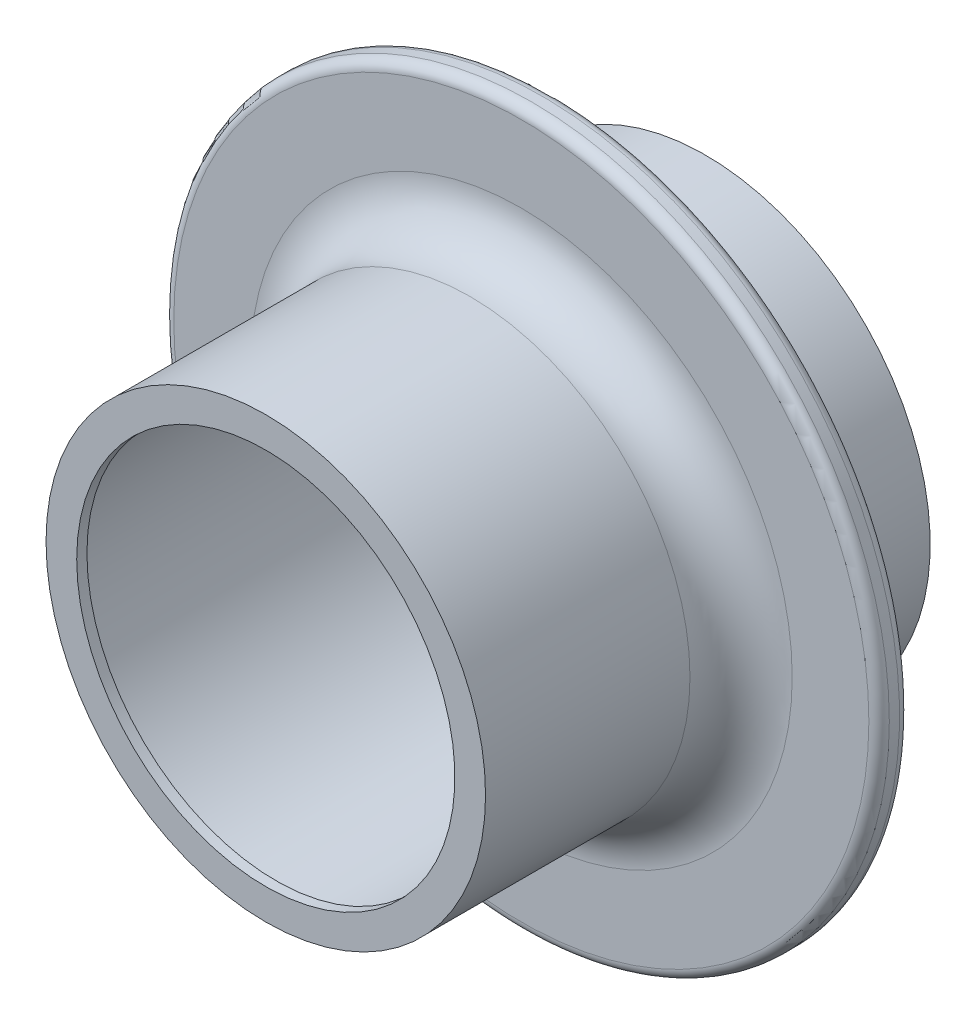
from build123d import *

# Parameters (mm, degrees)
SKETCH_1_R          = 35
EXTRUDE_1_DEPTH     = 43
SKETCH_2_R          = 35
SKETCH_2_R_2        = 22
CUT_EXTRUDE_1_DEPTH = 15
SKETCH_3_R          = 35
SKETCH_3_R_2        = 21.5
CUT_EXTRUDE_2_DEPTH = 25
SKETCH_4_R          = 18.5
CUT_EXTRUDE_3_DEPTH = 44
SKETCH_5_R          = 20
CUT_EXTRUDE_4_DEPTH = 42
FILLET_1_R          = 5
FILLET_2_R          = 1


with BuildPart() as part:
    # ｽｹｯﾁ1 → ﾎﾞｽ - 押し出し1 (new body)
    with BuildSketch(Plane.XY):
        Circle(SKETCH_1_R)
    extrude(amount=EXTRUDE_1_DEPTH)

    # ｽｹｯﾁ2 → ｶｯﾄ - 押し出し1 (cut)
    with BuildSketch(Plane(origin=(0, 0, 0), x_dir=(-1, 0, 0), z_dir=(0, 0, -1))):
        Circle(SKETCH_2_R)
        Circle(SKETCH_2_R_2, mode=Mode.SUBTRACT)
    extrude(amount=-CUT_EXTRUDE_1_DEPTH, mode=Mode.SUBTRACT)

    # ｽｹｯﾁ3 → ｶｯﾄ - 押し出し2 (cut)
    with BuildSketch(Plane.XY.offset(43)):
        Circle(SKETCH_3_R)
        Circle(SKETCH_3_R_2, mode=Mode.SUBTRACT)
    extrude(amount=-CUT_EXTRUDE_2_DEPTH, mode=Mode.SUBTRACT)

    # ｽｹｯﾁ4 → ｶｯﾄ - 押し出し3 (cut, through all)
    with BuildSketch(Plane(origin=(0, 0, 0), x_dir=(-1, 0, 0), z_dir=(0, 0, -1))):
        Circle(SKETCH_4_R)
    extrude(amount=-CUT_EXTRUDE_3_DEPTH, mode=Mode.SUBTRACT)

    # ｽｹｯﾁ5 → ｶｯﾄ - 押し出し4 (cut)
    with BuildSketch(Plane(origin=(0, 0, 0), x_dir=(-1, 0, 0), z_dir=(0, 0, -1))):
        Circle(SKETCH_5_R)
    extrude(amount=-CUT_EXTRUDE_4_DEPTH, mode=Mode.SUBTRACT)

    # ﾌｨﾚｯﾄ1
    fillet_1_edges = [part.edges().sort_by_distance(p)[0] for p in [
        (-21.5, 0, 18),
        (22, 0, 15),
    ]]
    fillet(fillet_1_edges, radius=FILLET_1_R)

    # ﾌｨﾚｯﾄ2
    fillet_2_edges = [part.edges().sort_by_distance(p)[0] for p in [
        (-35, 0, 18),
        (-35, 0, 15),
    ]]
    fillet(fillet_2_edges, radius=FILLET_2_R)


solid = part.part
